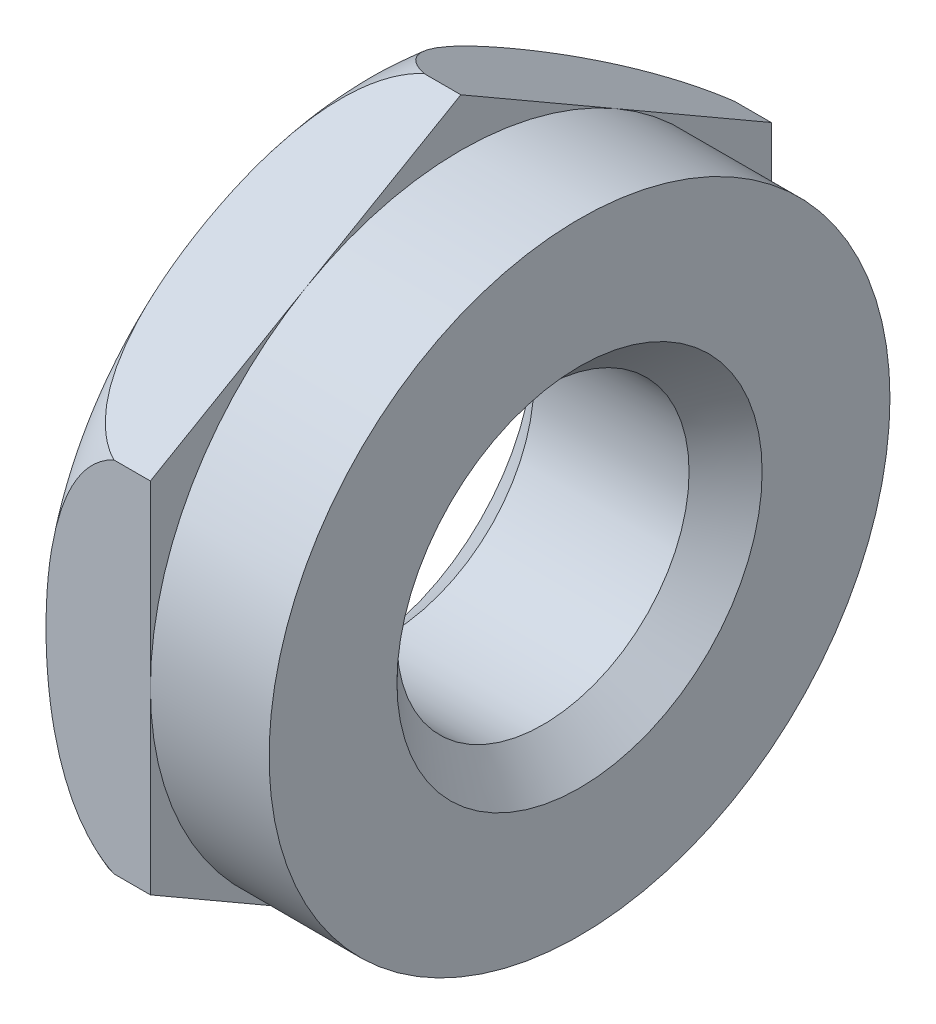
from build123d import *

# Parameters (mm, degrees)
ESQUISSE2_R             = 4
EXTRUSION1_DEPTH        = 3.25
EXTRUSION1_DEPTH_BACK   = 3
ESQUISSE3_OUTSIDE_W     = 24.342
ESQUISSE3_OUTSIDE_H     = 26.972
ESQUISSE3_OUTSIDE_R     = 8.5
ENL_V_MAT_EXTRU_1_DEPTH = 4.25
CHANFREIN1_SIZE         = 1


with BuildPart() as part:
    # Esquisse2 → Extrusion1 (new body, two sides)
    with BuildSketch(Plane(origin=(0, 0, 0), x_dir=(0, 0, -1), z_dir=(1, 0, 0))) as extrusion1_sk:
        Polygon((0, 9.814954576), (-8.5, 4.907477288), (-8.5, -4.907477288), (0, -9.814954576), (8.5, -4.907477288), (8.5, 4.907477288), align=None)
        Circle(ESQUISSE2_R, mode=Mode.SUBTRACT)
    extrude(amount=EXTRUSION1_DEPTH)
    extrude(extrusion1_sk.sketch, amount=-EXTRUSION1_DEPTH_BACK)

    # Esquisse3 outside → Enlèv. mat.-Extru.1 (cut, through all)
    with BuildSketch(Plane(origin=(0, 0, 0), x_dir=(0, 0, -1), z_dir=(1, 0, 0))):
        Rectangle(ESQUISSE3_OUTSIDE_W, ESQUISSE3_OUTSIDE_H)
        Circle(ESQUISSE3_OUTSIDE_R, mode=Mode.SUBTRACT)
    extrude(amount=ENL_V_MAT_EXTRU_1_DEPTH, mode=Mode.SUBTRACT)

    # Esquisse4 → Enlèvement de matière-Révolution1 (revolve, cut)
    with BuildSketch(Plane.XY, mode=Mode.PRIVATE) as enl_vement_de_mati_re_r_volution1_sk:
        with BuildLine():
            Line((-1, 9.814954576), (-3, 9.814954576))
            Line((-3, 9.814954576), (-3, 8.25))
            ThreePointArc((-3, 8.25), (-2.173757557, 9.25453812), (-1, 9.814954576))
        make_face()
    revolve(enl_vement_de_mati_re_r_volution1_sk.sketch.rotate(Axis((0, 0, 0), (-1, 0, 0)), 90), axis=Axis((0, 0, 0), (-1, 0, 0)), mode=Mode.SUBTRACT)  # turned: the seam where the file's is

    # Chanfrein1
    chanfrein1_edges = [part.edges().sort_by_distance(p)[0] for p in [
        (3.25, 0, 4),
        (-3, 0, 4),
    ]]
    chamfer(chanfrein1_edges, length=CHANFREIN1_SIZE)


solid = part.part
